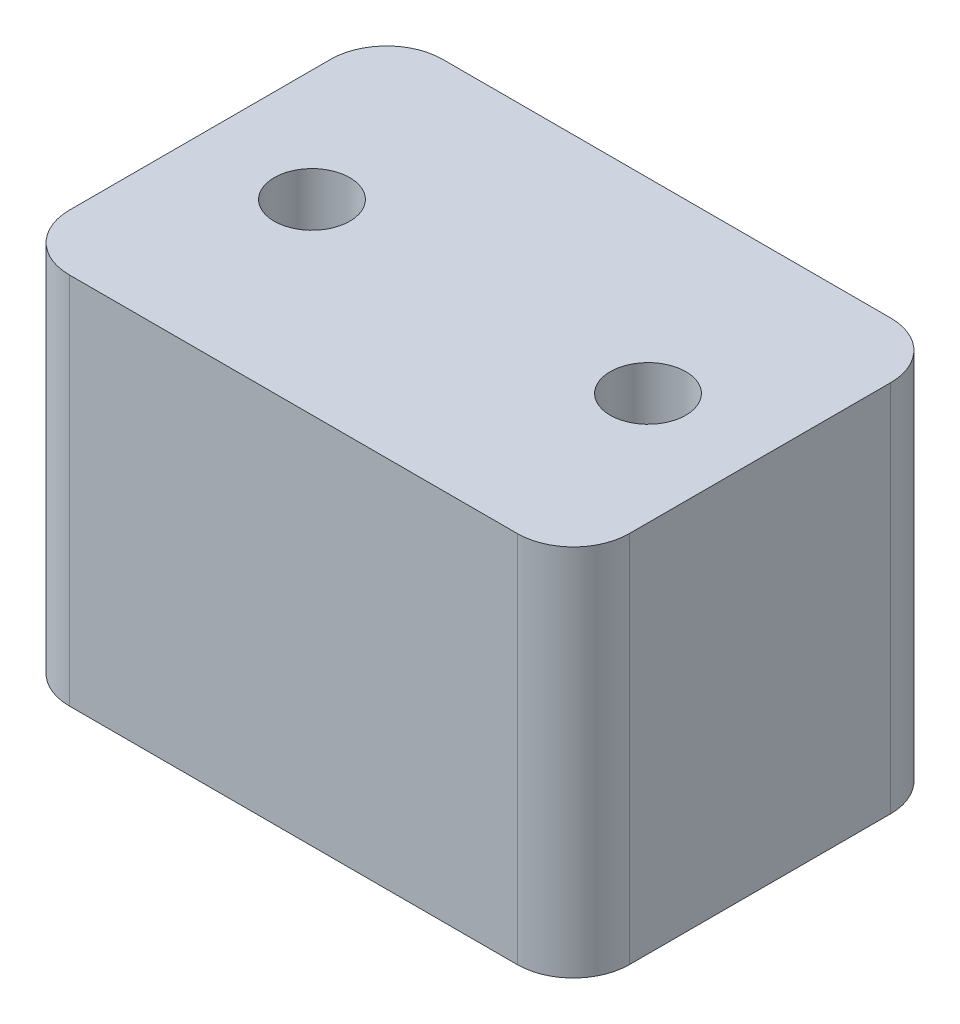
from build123d import *

# Parameters (mm, degrees)
SKETCH_1_W          = 30
SKETCH_1_H          = 20
EXTRUDE_1_DEPTH     = 20
SKETCH_2_R          = 2.025
CUT_EXTRUDE_1_DEPTH = 20
FILLET_1_R          = 3


with BuildPart() as part:
    # 草图1 → 凸台-拉伸1 (new body)
    with BuildSketch(Plane(origin=(0, 0, 0), x_dir=(1, 0, 0), z_dir=(0, 1, 0))):
        Rectangle(SKETCH_1_W, SKETCH_1_H)
    extrude(amount=EXTRUDE_1_DEPTH)

    # 草图2 → 切除-拉伸1 (cut)
    with BuildSketch(Plane(origin=(0, 20, 0), x_dir=(1, 0, 0), z_dir=(0, 1, 0))):
        with Locations((-9, 0)):
            Circle(SKETCH_2_R)
        with Locations((9, 0)):
            Circle(SKETCH_2_R)
    extrude(amount=-CUT_EXTRUDE_1_DEPTH, mode=Mode.SUBTRACT)

    # 圆角1
    fillet_1_edges = [part.edges().sort_by_distance(p)[0] for p in [
        (15, 10, 10),
        (-15, 10, 10),
        (-15, 10, -10),
        (15, 10, -10),
    ]]
    fillet(fillet_1_edges, radius=FILLET_1_R)


solid = part.part
